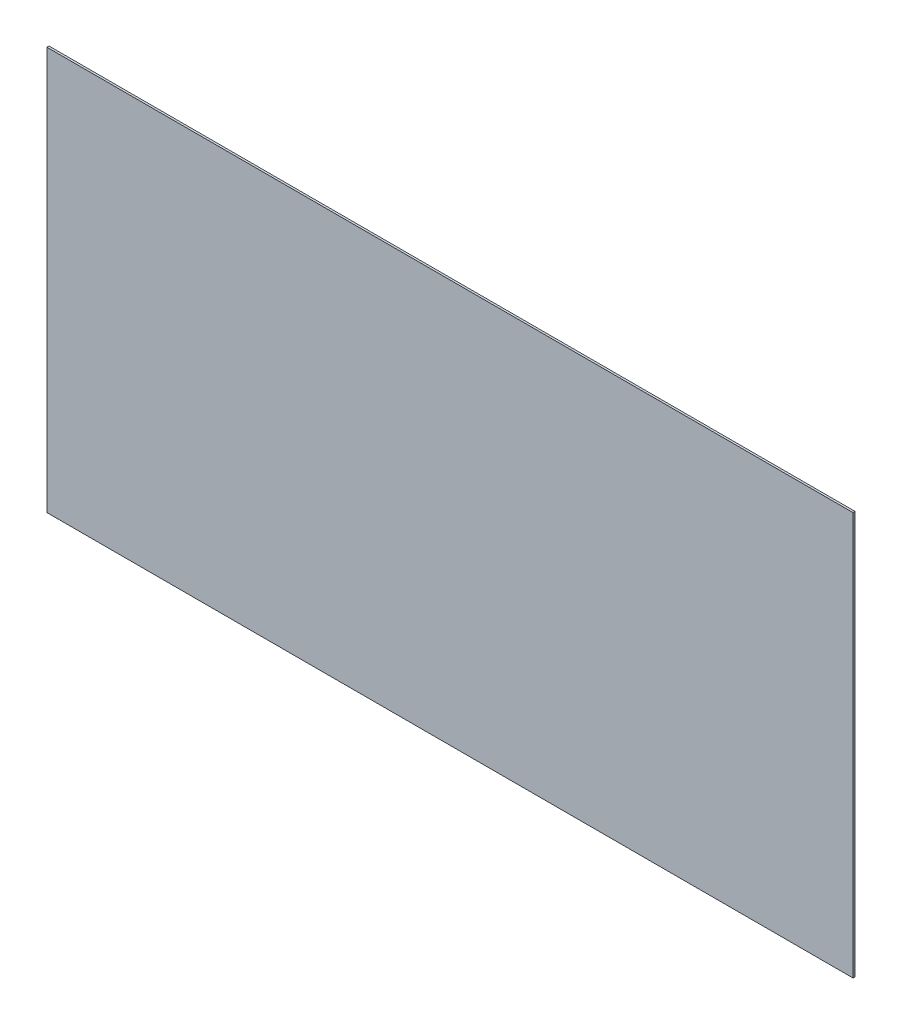
from build123d import *

# Parameters (mm, degrees)
SKETCH3_W           = 2438.4
SKETCH3_H           = 1219.2
BOSS_EXTRUDE1_DEPTH = 3.175


with BuildPart() as part:
    # Sketch3 → Boss-Extrude1 (new, symmetric)
    with BuildSketch(Plane.XY):
        Rectangle(SKETCH3_W, SKETCH3_H)
    extrude(amount=BOSS_EXTRUDE1_DEPTH, both=True)


solid = part.part
